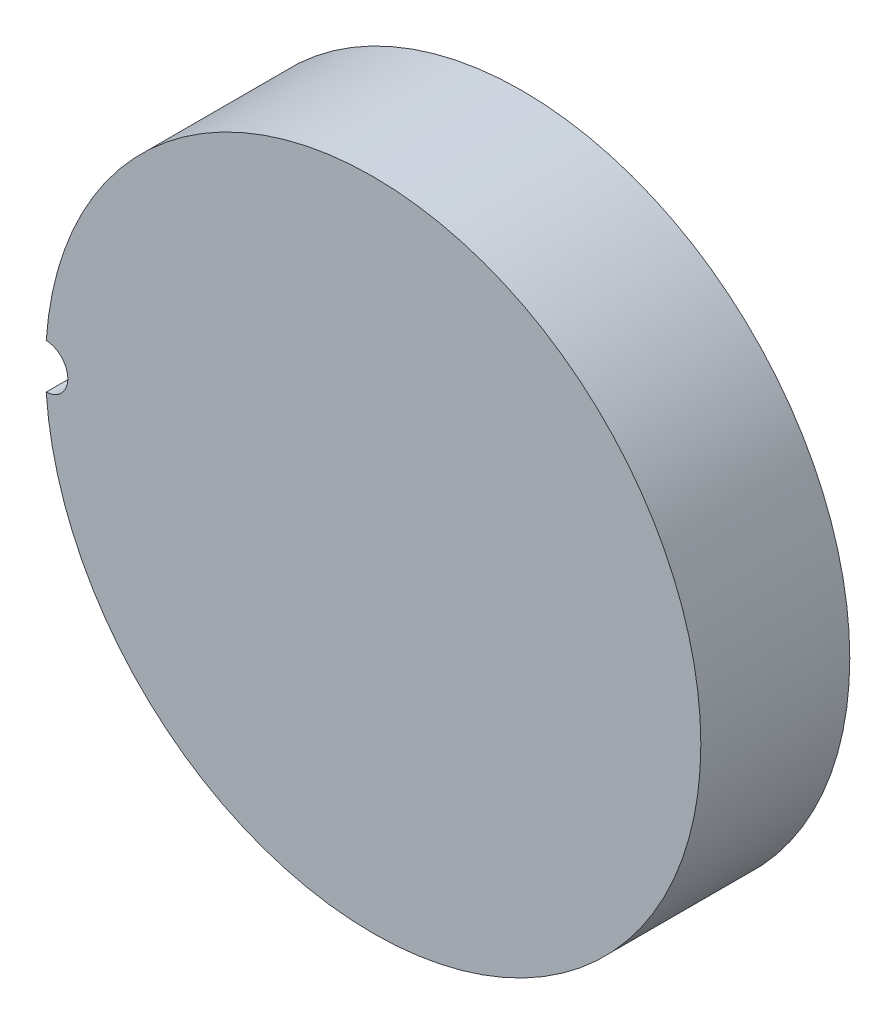
from build123d import *

# Parameters (mm, degrees)
SKETCH2_R          = 1.5
CUT_EXTRUDE1_DEPTH = 5


with BuildPart() as part:
    # Sketch1 → Revolve1 (revolve)
    with BuildSketch(Plane(origin=(0, 0, 0), x_dir=(1, 0, 0), z_dir=(0, 1, 0))):
        with BuildLine():
            Line((0, 15.894882233), (0, 0))
            Line((0, 0), (22, 0))
            Line((22, 0), (22, 10))
            ThreePointArc((22, 10), (11.388037985, 14.39561859), (0, 15.894882233))
        make_face()
    revolve(axis=Axis((0, 0, 18.671764029), (0, 0, -1)))

    # Sketch2 → Cut-Extrude1 (cut)
    with BuildSketch(Plane.XY):
        with Locations((-22, 0)):
            Circle(SKETCH2_R)
    extrude(amount=-CUT_EXTRUDE1_DEPTH, mode=Mode.SUBTRACT)


solid = part.part
